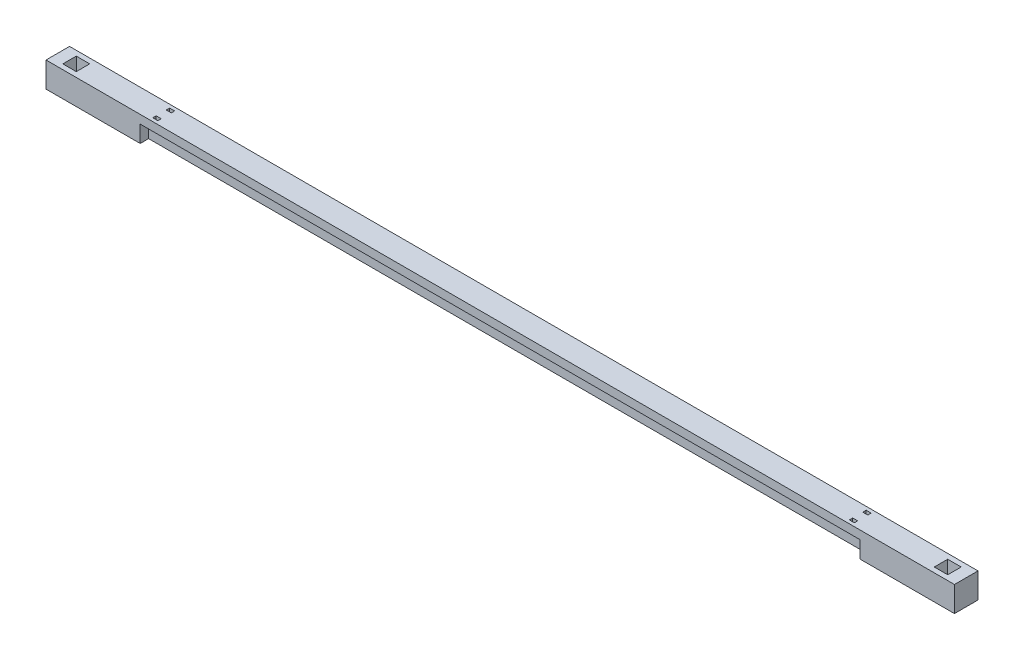
from build123d import *

# Parameters (mm, degrees)
SKETCH_1_W             = 5400
SKETCH_1_H             = 40
EXTRUDE_1_DEPTH        = 100
SKETCH_2_W             = 5400
SKETCH_2_H             = 140
EXTRUDE_2_DEPTH        = 50
SKETCH_3_W             = 30
SKETCH_3_H             = 20
CUT_EXTRUDE_1_DEPTH    = 51
PATTERN_LINEAR_1_COUNT = 2
PATTERN_LINEAR_1_PITCH = 4140
SKETCH_4_W             = 560
SKETCH_4_H             = 140
EXTRUDE_3_DEPTH        = 100
PATTERN_LINEAR_2_COUNT = 2
PATTERN_LINEAR_2_PITCH = 4840
SKETCH_5_W             = 80
SKETCH_5_H             = 80
CUT_EXTRUDE_2_DEPTH    = 100


with BuildPart() as part:
    # 草图1 → 凸台-拉伸1 (new body)
    with BuildSketch(Plane(origin=(0, 0, 0), x_dir=(1, 0, 0), z_dir=(0, 1, 0))):
        with Locations((2700, 20)):
            Rectangle(SKETCH_1_W, SKETCH_1_H)
    extrude(amount=EXTRUDE_1_DEPTH)

    # 草图2 → 凸台-拉伸2 (add)
    with BuildSketch(Plane(origin=(0, 100, 0), x_dir=(1, 0, 0), z_dir=(0, 1, 0))):
        with Locations((2700, 20)):
            Rectangle(SKETCH_2_W, SKETCH_2_H)
    extrude(amount=EXTRUDE_2_DEPTH)

    # 草图3 → 切除-拉伸1 (cut, through all)
    with BuildSketch(Plane.XZ.offset(-100)):
        with Locations((630, -60)):
            Rectangle(SKETCH_3_W, SKETCH_3_H)
        with Locations((630, 20)):
            Rectangle(SKETCH_3_W, SKETCH_3_H)
    cut_extrude_1 = extrude(amount=-CUT_EXTRUDE_1_DEPTH, mode=Mode.SUBTRACT)

    # 阵列(线性)1: 切除-拉伸1 ×2
    with Locations(*[(i * PATTERN_LINEAR_1_PITCH, 0, 0) for i in range(1, PATTERN_LINEAR_1_COUNT)]):
        add(cut_extrude_1, mode=Mode.SUBTRACT)

    # 草图4 → 凸台-拉伸3 (add)
    with BuildSketch(Plane.XZ):
        with Locations((5120, -20)):
            Rectangle(SKETCH_4_W, SKETCH_4_H)
    extrude_3 = extrude(amount=-EXTRUDE_3_DEPTH)

    # 阵列(线性)2: 凸台-拉伸3 ×2
    with Locations(*[(-i * PATTERN_LINEAR_2_PITCH, 0, 0) for i in range(1, PATTERN_LINEAR_2_COUNT)]):
        add(extrude_3)

    # 草图5 → 切除-拉伸2 (cut)
    with BuildSketch(Plane(origin=(0, 150, 0), x_dir=(1, 0, 0), z_dir=(0, 1, 0))):
        with Locations((5290, 20)):
            Rectangle(SKETCH_5_W, SKETCH_5_H)
    cut_extrude_2 = extrude(amount=-CUT_EXTRUDE_2_DEPTH, mode=Mode.SUBTRACT)

    # 镜向1: 切除-拉伸2 across plane
    add(cut_extrude_2.mirror(Plane(origin=(2700, 0, 0), x_dir=(0, 0, 1), z_dir=(1, 0, 0))), mode=Mode.SUBTRACT)


solid = part.part
